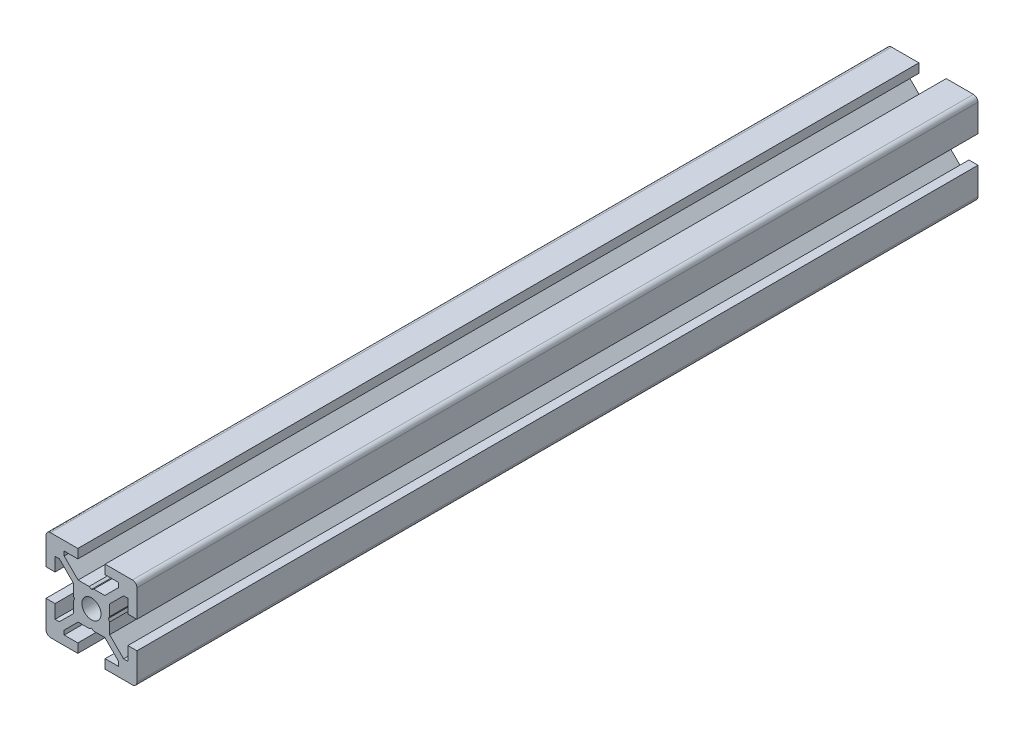
from build123d import *

# Parameters (mm, degrees)
EXTRUDE_1_DEPTH = 185
SKETCH_2_W      = 260
SKETCH_2_H      = 2.1


with BuildPart() as part:
    # ｽｹｯﾁ1 → ﾎﾞｽ - 押し出し1 (new body)
    with BuildSketch(Plane.XY):
        with BuildLine():
            Line((-10, -3), (-10, -9))
            ThreePointArc((-10, -9), (-9.707106781, -9.707106781), (-9, -10))
            Line((-9, -10), (-3, -10))
            Line((-3, -10), (-3, -8))
            Line((-3, -8), (-6, -8))
            Line((-6, -8), (-6, -7.060660172))
            Line((-6, -7.060660172), (-2.939339828, -4))
            Line((-2.939339828, -4), (-0.519615242, -4))
            Line((-0.519615242, -4), (0, -3.7))
            Line((0, -3.7), (0.519615242, -4))
            Line((0.519615242, -4), (2.939339828, -4))
            Line((2.939339828, -4), (6, -7.060660172))
            Line((6, -7.060660172), (6, -8))
            Line((6, -8), (3, -8))
            Line((3, -8), (3, -10))
            Line((3, -10), (9, -10))
            ThreePointArc((9, -10), (9.707106781, -9.707106781), (10, -9))
            Line((10, -9), (10, -3))
            Line((10, -3), (8, -3))
            Line((8, -3), (8, -6))
            Line((8, -6), (7.060660172, -6))
            Line((7.060660172, -6), (4, -2.939339828))
            Line((4, -2.939339828), (4, -0.519615242))
            Line((4, -0.519615242), (3.7, 0))
            Line((3.7, 0), (4, 0.519615242))
            Line((4, 0.519615242), (4, 2.939339828))
            Line((4, 2.939339828), (7.060660172, 6))
            Line((7.060660172, 6), (8, 6))
            Line((8, 6), (8, 3))
            Line((8, 3), (10, 3))
            Line((10, 3), (10, 9))
            ThreePointArc((10, 9), (9.707106781, 9.707106781), (9, 10))
            Line((9, 10), (3, 10))
            Line((3, 10), (3, 8))
            Line((3, 8), (6, 8))
            Line((6, 8), (6, 7.060660172))
            Line((6, 7.060660172), (2.939339828, 4))
            Line((2.939339828, 4), (0.519615242, 4))
            Line((0.519615242, 4), (0, 3.7))
            Line((0, 3.7), (-0.519615242, 4))
            Line((-0.519615242, 4), (-2.939339828, 4))
            Line((-2.939339828, 4), (-6, 7.060660172))
            Line((-6, 7.060660172), (-6, 8))
            Line((-6, 8), (-3, 8))
            Line((-3, 8), (-3, 10))
            Line((-3, 10), (-9, 10))
            ThreePointArc((-9, 10), (-9.707106781, 9.707106781), (-10, 9))
            Line((-10, 9), (-10, 3))
            Line((-10, 3), (-8, 3))
            Line((-8, 3), (-8, 6))
            Line((-8, 6), (-7.060660172, 6))
            Line((-7.060660172, 6), (-4, 2.939339828))
            Line((-4, 2.939339828), (-4, 0.519615242))
            Line((-4, 0.519615242), (-3.7, 0))
            Line((-3.7, 0), (-4, -0.519615242))
            Line((-4, -0.519615242), (-4, -2.939339828))
            Line((-4, -2.939339828), (-7.060660172, -6))
            Line((-7.060660172, -6), (-8, -6))
            Line((-8, -6), (-8, -3))
            Line((-8, -3), (-10, -3))
        make_face()
    extrude(amount=-EXTRUDE_1_DEPTH)

    # ｽｹｯﾁ2 → ｶｯﾄ - 回転1 (revolve, cut)
    with BuildSketch(Plane(origin=(0, 0, 0), x_dir=(0, 0, -1), z_dir=(1, 0, 0))):
        with Locations((130, 1.05)):
            Rectangle(SKETCH_2_W, SKETCH_2_H)
    revolve(axis=Axis((0, 0, -260), (0, 0, 1)), mode=Mode.SUBTRACT)


solid = part.part
